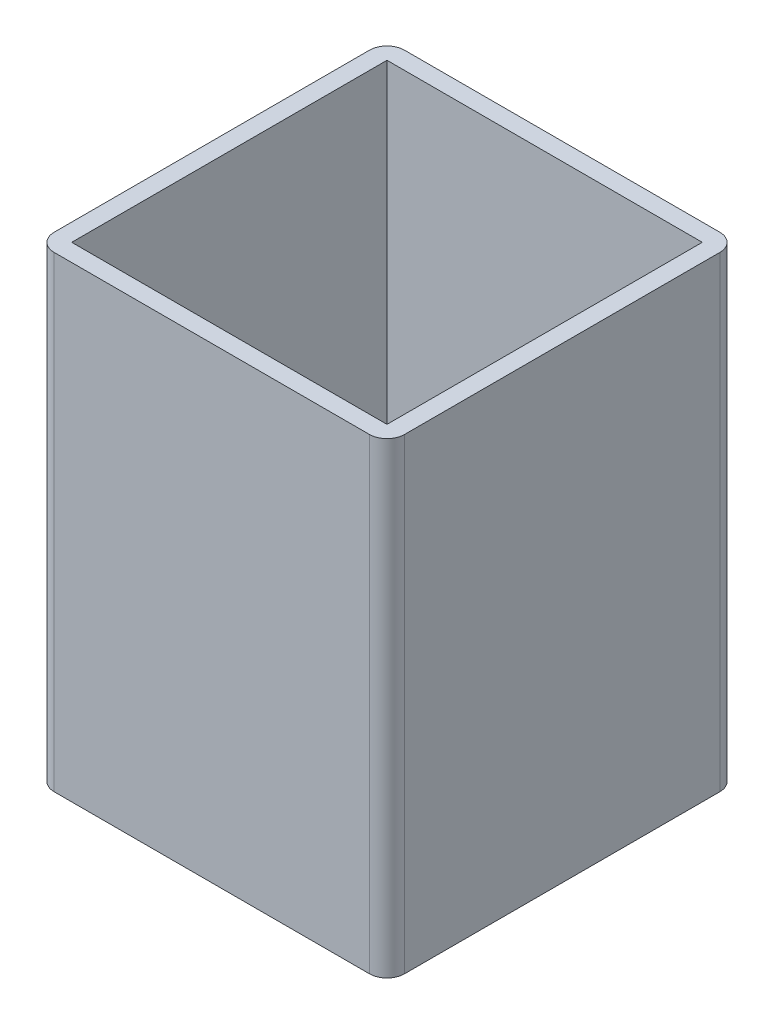
from build123d import *

# Parameters (mm, degrees)
SKETCH1_W           = 60
SKETCH1_H           = 60
SKETCH1_W_2         = 54
SKETCH1_H_2         = 54
BOSS_EXTRUDE1_DEPTH = 80
FILLET2_R           = 3


with BuildPart() as part:
    # Sketch1 → Boss-Extrude1 (new body)
    with BuildSketch(Plane(origin=(0, 0, 0), x_dir=(1, 0, 0), z_dir=(0, 1, 0))):
        with Locations((30, 30)):
            Rectangle(SKETCH1_W, SKETCH1_H)
        with Locations((30, 30)):
            Rectangle(SKETCH1_W_2, SKETCH1_H_2, mode=Mode.SUBTRACT)
    extrude(amount=BOSS_EXTRUDE1_DEPTH)

    # Fillet2
    fillet2_edges = [part.edges().sort_by_distance(p)[0] for p in [
        (0, 40, -60),
        (60, 40, -60),
        (60, 40, 0),
        (0, 40, 0),
    ]]
    fillet(fillet2_edges, radius=FILLET2_R)


solid = part.part
